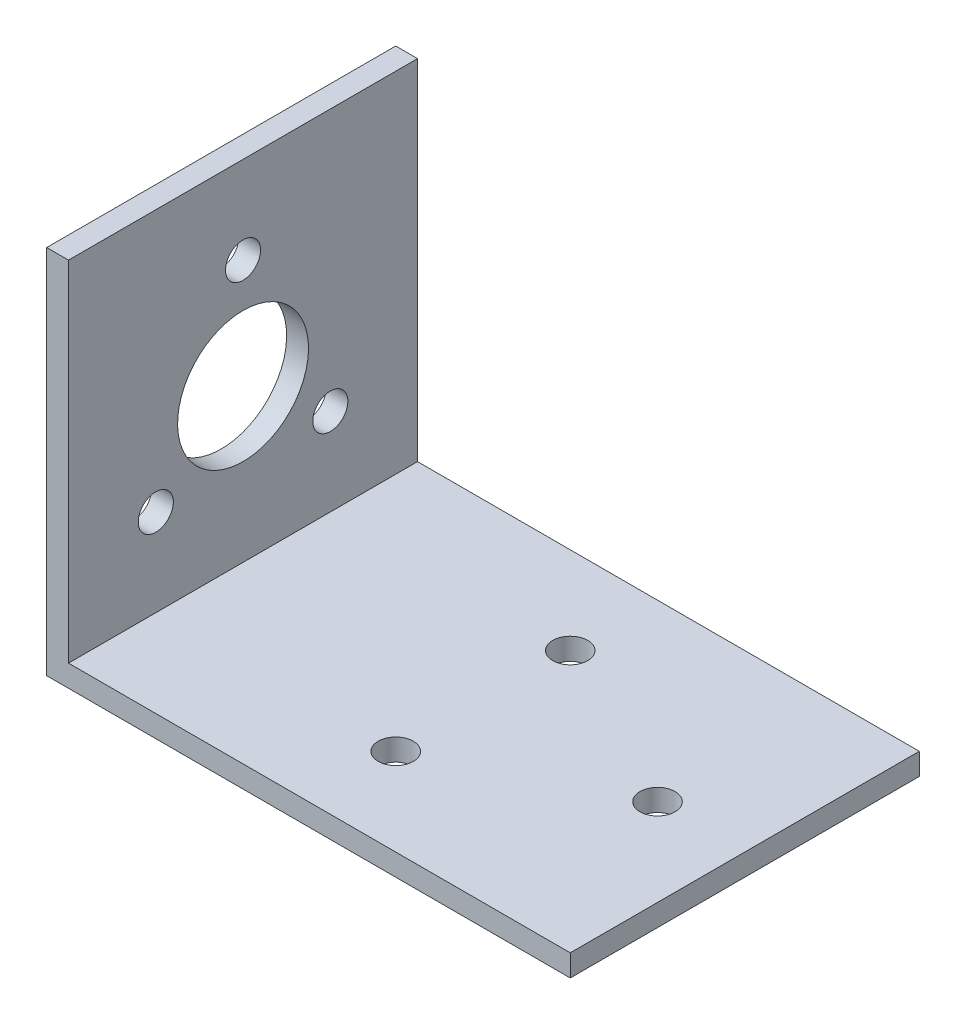
from build123d import *

# Parameters (mm, degrees)
BOSS_EXTRUDE1_DEPTH = 50.8
SKETCH2_R           = 2.5527
CUT_EXTRUDE1_DEPTH  = 50.8
SKETCH3_R           = 2.5527
CUT_EXTRUDE2_DEPTH  = 50.8
SKETCH4_R           = 9.525
CUT_EXTRUDE3_DEPTH  = 3.175


with BuildPart() as part:
    # Sketch1 → Boss-Extrude1 (new body)
    with BuildSketch(Plane.XY):
        Polygon((0, 0), (-3.175, 0), (-3.175, 53.975), (0, 53.975), (0, 3.175), (73.025, 3.175), (73.025, 0), align=None)
    extrude(amount=BOSS_EXTRUDE1_DEPTH)

    # Sketch2 → Cut-Extrude1 (cut)
    with BuildSketch(Plane(origin=(0, 0, 0), x_dir=(0, 0, -1), z_dir=(1, 0, 0))):
        with Locations((-25.4, 41.275)):
            Circle(SKETCH2_R)
        with Locations((-38.1, 15.875)):
            Circle(SKETCH2_R)
        with Locations((-12.7, 15.875)):
            Circle(SKETCH2_R)
    extrude(amount=-CUT_EXTRUDE1_DEPTH, mode=Mode.SUBTRACT)

    # Sketch3 → Cut-Extrude2 (cut)
    with BuildSketch(Plane(origin=(0, 3.175, 0), x_dir=(1, 0, 0), z_dir=(0, 1, 0))):
        with Locations((60.325, -25.4)):
            Circle(SKETCH3_R)
        with Locations((34.925, -12.7)):
            Circle(SKETCH3_R)
        with Locations((34.925, -38.1)):
            Circle(SKETCH3_R)
    extrude(amount=-CUT_EXTRUDE2_DEPTH, mode=Mode.SUBTRACT)

    # Sketch4 → Cut-Extrude3 (cut)
    with BuildSketch(Plane(origin=(0, 0, 0), x_dir=(0, 0, -1), z_dir=(1, 0, 0))):
        with Locations((-25.4, 25.4)):
            Circle(SKETCH4_R)
    extrude(amount=-CUT_EXTRUDE3_DEPTH, mode=Mode.SUBTRACT)


solid = part.part
